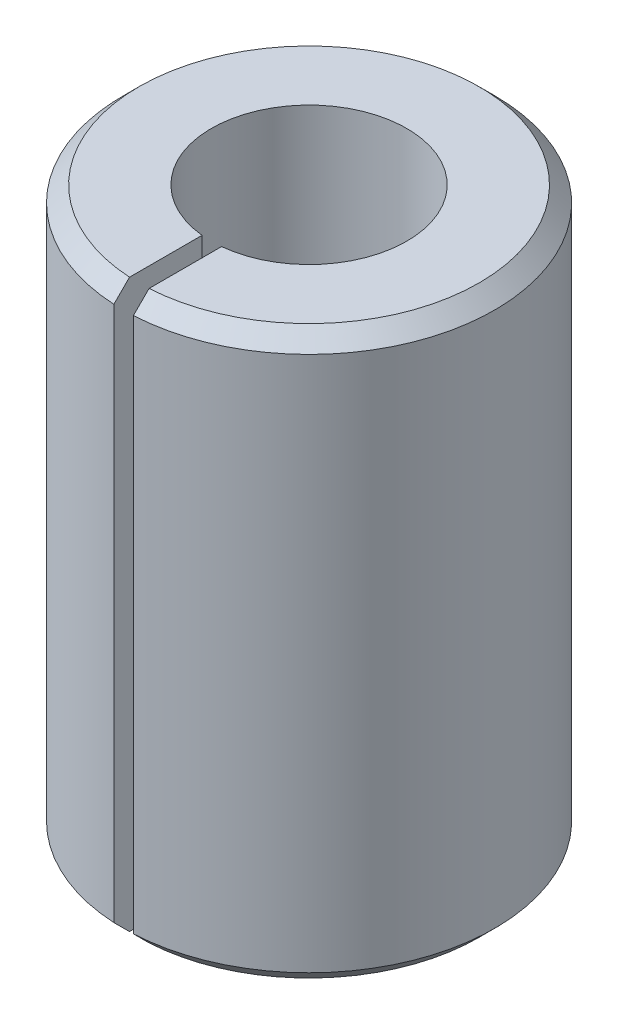
from build123d import *

# Parameters (mm, degrees)
BOSS_EXTRUDE1_DEPTH = 29
CHAMFER1_SIZE       = 0.8


with BuildPart() as part:
    # Sketch1 → Boss-Extrude1 (new body)
    with BuildSketch(Plane(origin=(0, 0, 0), x_dir=(1, 0, 0), z_dir=(0, 1, 0))):
        with BuildLine():
            Line((-0.5, -5), (-0.5, -9.486832981))
            ThreePointArc((-0.5, -9.486832981), (0, 9.5), (0.5, -9.486832981))
            Line((0.5, -9.486832981), (0.5, -5))
            Line((0.5, -5), (0.5, -4.974937186))
            ThreePointArc((0.5, -4.974937186), (0, 5), (-0.5, -4.974937186))
            Line((-0.5, -4.974937186), (-0.5, -5))
        make_face()
    extrude(amount=BOSS_EXTRUDE1_DEPTH)

    # Chamfer1
    chamfer1_edges = [part.edges().sort_by_distance(p)[0] for p in [
        (0, 29, -9.5),
        (0, 0, -9.5),
    ]]
    chamfer(chamfer1_edges, length=CHAMFER1_SIZE)


solid = part.part
